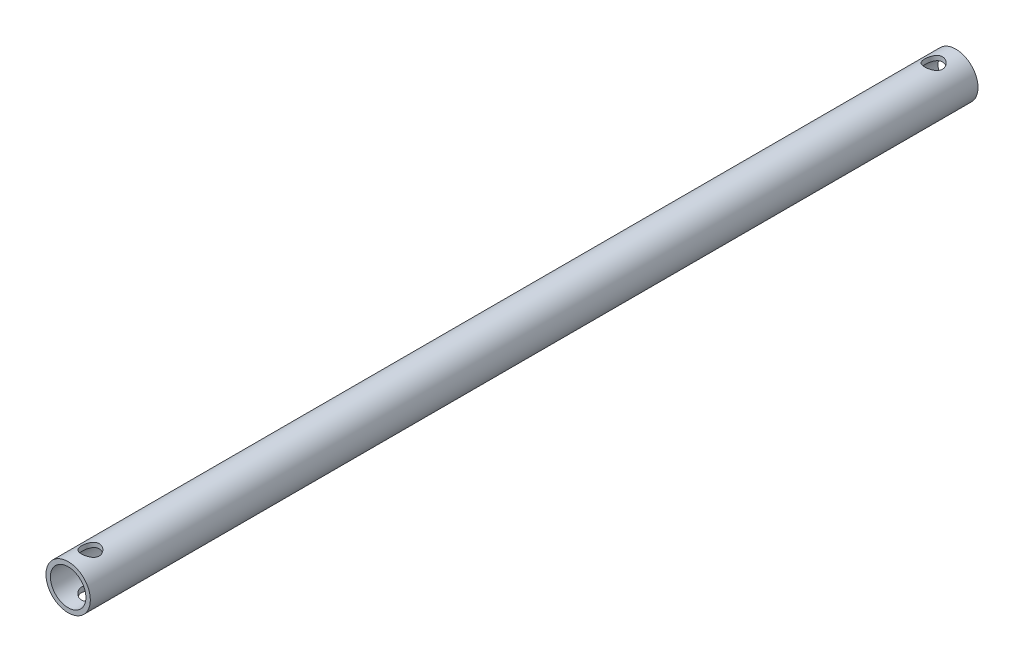
from build123d import *

# Parameters (mm, degrees)
SKETCH_1_R               = 10
SKETCH_1_R_2             = 8
EXTRUDE_1_DEPTH          = 400
SKETCH_2_R               = 4
CUT_EXTRUDE_1_DEPTH      = 11
CUT_EXTRUDE_1_DEPTH_BACK = 11


with BuildPart() as part:
    # 草图1 → 凸台-拉伸1 (new body)
    with BuildSketch(Plane.XY):
        Circle(SKETCH_1_R)
        Circle(SKETCH_1_R_2, mode=Mode.SUBTRACT)
    extrude(amount=EXTRUDE_1_DEPTH)

    # 草图2 → 切除-拉伸1 (cut, two sides)
    with BuildSketch(Plane(origin=(0, 0, 0), x_dir=(1, 0, 0), z_dir=(0, 1, 0))) as cut_extrude_1_sk:
        with Locations((0, -10)):
            Circle(SKETCH_2_R)
        with Locations((0, -390)):
            Circle(SKETCH_2_R)
    extrude(amount=CUT_EXTRUDE_1_DEPTH, mode=Mode.SUBTRACT)
    extrude(cut_extrude_1_sk.sketch, amount=-CUT_EXTRUDE_1_DEPTH_BACK, mode=Mode.SUBTRACT)


solid = part.part
